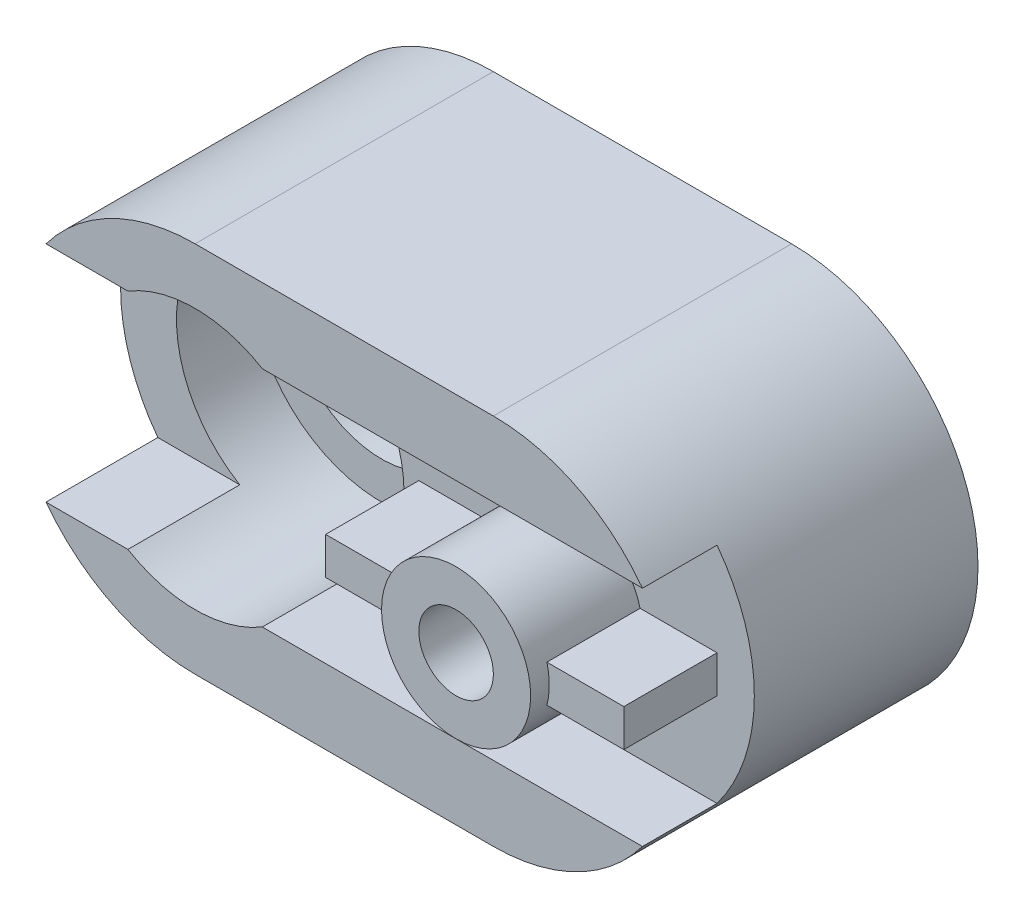
from build123d import *

# Parameters (mm, degrees)
BOSS_EXTRUDE1_DEPTH        = 80
SKETCH2_W                  = 20
SKETCH2_H                  = 10
CUT_EXTRUDE1_DEPTH         = 209
SKETCH3_R                  = 10
CUT_EXTRUDE2_DEPTH         = 40
SKETCH4_R                  = 20
SKETCH4_R_2                = 10
BOSS_EXTRUDE2_DEPTH        = 10
F_20_0MM_DOWEL_HOLE1_D     = 20
F_20_0MM_DOWEL_HOLE1_DEPTH = 50
F_20_0MM_DOWEL_HOLE1_TIP   = 6.00860619
CUT_EXTRUDE3_DEPTH         = 20
SKETCH10_R                 = 10
CUT_EXTRUDE4_DEPTH         = 74
SKETCH11_R                 = 25
SKETCH11_R_2               = 10
CUT_EXTRUDE5_DEPTH         = 40
SKETCH12_R                 = 25
CUT_EXTRUDE6_DEPTH         = 10
SKETCH14_R                 = 35
SKETCH14_R_2               = 25
CUT_EXTRUDE7_DEPTH         = 30
SKETCH15_R                 = 35
CUT_EXTRUDE8_DEPTH         = 30
CUT_EXTRUDE9_DEPTH         = 20
SKETCH17_W                 = 20
SKETCH17_H                 = 5
BOSS_EXTRUDE3_DEPTH        = 25
SKETCH18_W                 = 20
SKETCH18_H                 = 5
BOSS_EXTRUDE4_DEPTH        = 25
SKETCH19_W                 = 20
SKETCH19_H                 = 5
BOSS_EXTRUDE5_DEPTH        = 25


with BuildPart() as part:
    # Sketch1 → Boss-Extrude1 (new body)
    with BuildSketch(Plane.XY):
        with BuildLine():
            ThreePointArc((0, 50), (14.644660941, 14.644660941), (50, 0))
            Line((50, 0), (130, 0))
            ThreePointArc((130, 0), (165.355339059, 14.644660941), (180, 50))
            ThreePointArc((180, 50), (165.355339059, 85.355339059), (130, 100))
            Line((130, 100), (50, 100))
            ThreePointArc((50, 100), (14.644660941, 85.355339059), (0, 50))
        make_face()
    extrude(amount=BOSS_EXTRUDE1_DEPTH)

    # Sketch2 → Cut-Extrude1 (cut)
    with BuildSketch(Plane(origin=(0, 0, 0), x_dir=(0, 0, -1), z_dir=(1, 0, 0))):
        with Locations((-70, 75)):
            Rectangle(SKETCH2_W, SKETCH2_H)
        with Locations((-70, 25)):
            Rectangle(SKETCH2_W, SKETCH2_H)
    extrude(amount=CUT_EXTRUDE1_DEPTH, mode=Mode.SUBTRACT)

    # Sketch3 → Cut-Extrude2 (cut)
    with BuildSketch(Plane.XY.offset(80)):
        with Locations((130, 50)):
            Circle(SKETCH3_R)
    extrude(amount=-CUT_EXTRUDE2_DEPTH, mode=Mode.SUBTRACT)

    # Sketch4 → Boss-Extrude2 (add)
    with BuildSketch(Plane.XY.offset(80)):
        with Locations(Location((130, 50, 0), (0, 0, 270))):
            Circle(SKETCH4_R)
        with Locations((130, 50)):
            Circle(SKETCH4_R_2, mode=Mode.SUBTRACT)
    extrude(amount=BOSS_EXTRUDE2_DEPTH)

    # Ø20.0mm Dowel Hole1
    with Locations(Plane(origin=(130, 50, 90), x_dir=(1, 0, 0), z_dir=(0, 0, 1))):
        with Locations((0, 0)):
            Hole(F_20_0MM_DOWEL_HOLE1_D / 2, depth=F_20_0MM_DOWEL_HOLE1_DEPTH)
            with Locations((0, 0, -(F_20_0MM_DOWEL_HOLE1_DEPTH + F_20_0MM_DOWEL_HOLE1_TIP / 2))):  # 118° drill point
                Cone(0, F_20_0MM_DOWEL_HOLE1_D / 2, F_20_0MM_DOWEL_HOLE1_TIP, mode=Mode.SUBTRACT)

    # Sketch9 → Cut-Extrude3 (cut)
    with BuildSketch(Plane.XY.offset(80)):
        with BuildLine():
            Line((130, 70), (4.17424305, 70))
            ThreePointArc((4.17424305, 70), (0, 50), (4.17424305, 30))
            Line((4.17424305, 30), (130, 30))
            ThreePointArc((130, 30), (110, 50), (130, 70))
        make_face()
    extrude(amount=-CUT_EXTRUDE3_DEPTH, mode=Mode.SUBTRACT)

    # Sketch10 → Cut-Extrude4 (cut)
    with BuildSketch(Plane.XY.offset(60)):
        with Locations((50, 50)):
            Circle(SKETCH10_R)
    extrude(amount=-CUT_EXTRUDE4_DEPTH, mode=Mode.SUBTRACT)

    # Sketch11 → Cut-Extrude5 (cut)
    with BuildSketch(Plane.XY.offset(60)):
        with Locations((50, 50)):
            Circle(SKETCH11_R)
        with Locations((50, 50)):
            Circle(SKETCH11_R_2, mode=Mode.SUBTRACT)
    extrude(amount=-CUT_EXTRUDE5_DEPTH, mode=Mode.SUBTRACT)

    # Sketch12 → Cut-Extrude6 (cut)
    with BuildSketch(Plane.XY.offset(60)):
        with BuildLine():
            Line((70, 80), (10, 80))
            ThreePointArc((10, 80), (0, 50), (10, 20))
            Line((10, 20), (70, 20))
            ThreePointArc((70, 20), (86.055512755, 50), (70, 80))
        make_face()
        with Locations((50, 50)):
            Circle(SKETCH12_R, mode=Mode.SUBTRACT)
    extrude(amount=-CUT_EXTRUDE6_DEPTH, mode=Mode.SUBTRACT)

    # Sketch14 → Cut-Extrude7 (cut)
    with BuildSketch(Plane.XY.offset(60)):
        with Locations((50, 50)):
            Circle(SKETCH14_R)
        with Locations((50, 50)):
            Circle(SKETCH14_R_2, mode=Mode.SUBTRACT)
    extrude(amount=-CUT_EXTRUDE7_DEPTH, mode=Mode.SUBTRACT)

    # Sketch15 → Cut-Extrude8 (cut)
    with BuildSketch(Plane.XY.offset(80)):
        with Locations((50, 50)):
            Circle(SKETCH15_R)
    extrude(amount=-CUT_EXTRUDE8_DEPTH, mode=Mode.SUBTRACT)

    # Sketch16 → Cut-Extrude9 (cut)
    with BuildSketch(Plane.XY.offset(80)):
        with BuildLine():
            Line((130, 70), (175.82575695, 70))
            ThreePointArc((175.82575695, 70), (180, 50), (175.82575695, 30))
            Line((175.82575695, 30), (130, 30))
            ThreePointArc((130, 30), (150, 50), (130, 70))
        make_face()
    extrude(amount=-CUT_EXTRUDE9_DEPTH, mode=Mode.SUBTRACT)

    # Sketch17 → Boss-Extrude3 (add)
    with BuildSketch(Plane.XY.offset(60)):
        with BuildLine():
            Line((150, 45), (150, 50))
            ThreePointArc((150, 50), (149.840593925, 47.47991415), (149.364916731, 45))
            Line((149.364916731, 45), (150, 45))
        make_face()
        with Locations((160, 47.5)):
            Rectangle(SKETCH17_W, SKETCH17_H)
        with BuildLine():
            ThreePointArc((110.635083269, 45), (110.159406075, 47.47991415), (110, 50))
            Line((110, 50), (110, 45))
            Line((110, 45), (110.635083269, 45))
        make_face()
        with Locations((100, 47.5)):
            Rectangle(SKETCH17_W, SKETCH17_H)
    extrude(amount=BOSS_EXTRUDE3_DEPTH)

    # Sketch18 → Boss-Extrude4 (add)
    with BuildSketch(Plane.XY.offset(85)):
        with BuildLine():
            ThreePointArc((110.635083269, 55), (110.159406075, 52.52008585), (110, 50))
            Line((110, 50), (110, 55))
            Line((110, 55), (110.635083269, 55))
        make_face()
        with Locations((100, 52.5)):
            Rectangle(SKETCH18_W, SKETCH18_H)
    extrude(amount=-BOSS_EXTRUDE4_DEPTH)

    # Sketch19 → Boss-Extrude5 (add)
    with BuildSketch(Plane.XY.offset(85)):
        with BuildLine():
            Line((150, 55), (149.364916731, 55))
            ThreePointArc((149.364916731, 55), (149.840593925, 52.52008585), (150, 50))
            Line((150, 50), (150, 55))
        make_face()
        with Locations((160, 52.5)):
            Rectangle(SKETCH19_W, SKETCH19_H)
    extrude(amount=-BOSS_EXTRUDE5_DEPTH)


solid = part.part
